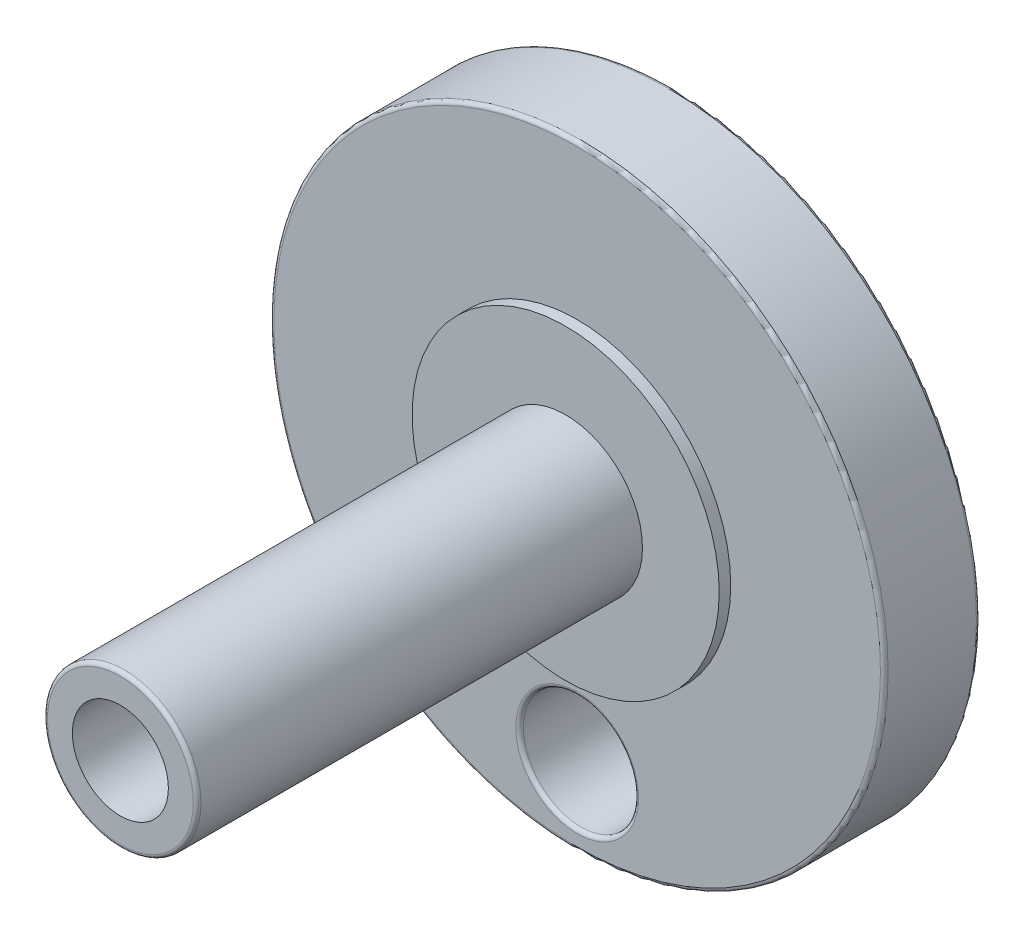
from build123d import *

# Parameters (mm, degrees)
SKETCH1_R                 = 8
BOSS_EXTRUDE1_DEPTH       = 2.5
SKETCH3_R                 = 4
BOSS_EXTRUDE2_DEPTH       = 0.3
SKETCH4_R                 = 2
BOSS_EXTRUDE3_DEPTH       = 11.6
M3X0_5_TAPPED_HOLE1_D     = 2.5
M3X0_5_TAPPED_HOLE1_DEPTH = 8.5
M3X0_5_TAPPED_HOLE1_TIP   = 0.751075774
SKETCH7_R                 = 1.5
CUT_EXTRUDE1_DEPTH        = 12.9
CUT_EXTRUDE1_DEPTH_BACK   = 3.5
FILLET1_R                 = 0.1


with BuildPart() as part:
    # Sketch1 → Boss-Extrude1 (new body)
    with BuildSketch(Plane.XY):
        Circle(SKETCH1_R)
    extrude(amount=BOSS_EXTRUDE1_DEPTH)

    # Sketch3 → Boss-Extrude2 (add)
    with BuildSketch(Plane.XY.offset(2.5)):
        Circle(SKETCH3_R)
    extrude(amount=BOSS_EXTRUDE2_DEPTH)

    # Sketch4 → Boss-Extrude3 (add)
    with BuildSketch(Plane.XY.offset(2.8)):
        Circle(SKETCH4_R)
    extrude(amount=BOSS_EXTRUDE3_DEPTH)

    # M3x0.5 Tapped Hole1
    with Locations(Plane.XY.offset(14.4)):
        with Locations((0, 0)):
            Hole(M3X0_5_TAPPED_HOLE1_D / 2, depth=M3X0_5_TAPPED_HOLE1_DEPTH)
            with Locations((0, 0, -(M3X0_5_TAPPED_HOLE1_DEPTH + M3X0_5_TAPPED_HOLE1_TIP / 2))):  # 118° drill point
                Cone(0, M3X0_5_TAPPED_HOLE1_D / 2, M3X0_5_TAPPED_HOLE1_TIP, mode=Mode.SUBTRACT)

    # Sketch7 → Cut-Extrude1 (cut, two sides)
    with BuildSketch(Plane.XY.offset(2.5)) as cut_extrude1_sk:
        with Locations((0, -6)):
            Circle(SKETCH7_R)
    extrude(amount=CUT_EXTRUDE1_DEPTH, mode=Mode.SUBTRACT)
    extrude(cut_extrude1_sk.sketch, amount=-CUT_EXTRUDE1_DEPTH_BACK, mode=Mode.SUBTRACT)

    # Fillet1
    fillet1_edges = [part.edges().sort_by_distance(p)[0] for p in [
        (-2, 0, 14.4),
        (-8, 0, 0),
        (-1.5, -6, 2.5),
        (-1.5, -6, 0),
        (-8, 0, 2.5),
    ]]
    fillet(fillet1_edges, radius=FILLET1_R)


solid = part.part
